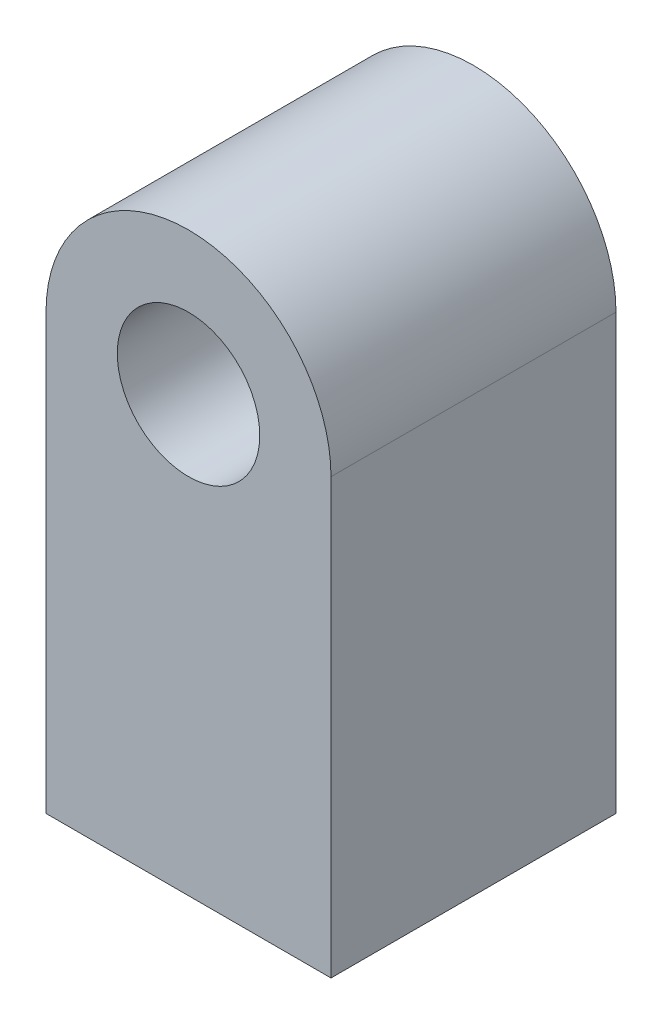
from build123d import *

# Parameters (mm, degrees)
SKETCH1_LINK1_R     = 20
BOSS_EXTRUDE1_DEPTH = 40
SKETCH2_LINK1_R     = 20
CUT_EXTRUDE1_DEPTH  = 40


with BuildPart() as part:
    # sketch1_link1 → Boss-Extrude1 (new body, symmetric)
    with BuildSketch(Plane.XY):
        with BuildLine():
            Line((-40, 0), (-40, 121.875))
            ThreePointArc((-40, 121.875), (0, 161.875), (40, 121.875))
            Line((40, 121.875), (40, 0))
            Line((40, 0), (0, 0))
            Line((0, 0), (-40, 0))
        make_face()
        with Locations((0, 121.875)):
            Circle(SKETCH1_LINK1_R, mode=Mode.SUBTRACT)
    extrude(amount=BOSS_EXTRUDE1_DEPTH, both=True)

    # sketch2_link1 → Cut-Extrude1 (cut)
    with BuildSketch(Plane(origin=(0, 0, 0), x_dir=(1, 0, 0), z_dir=(0, 1, 0))):
        Circle(SKETCH2_LINK1_R)
    extrude(amount=CUT_EXTRUDE1_DEPTH, mode=Mode.SUBTRACT)


solid = part.part
